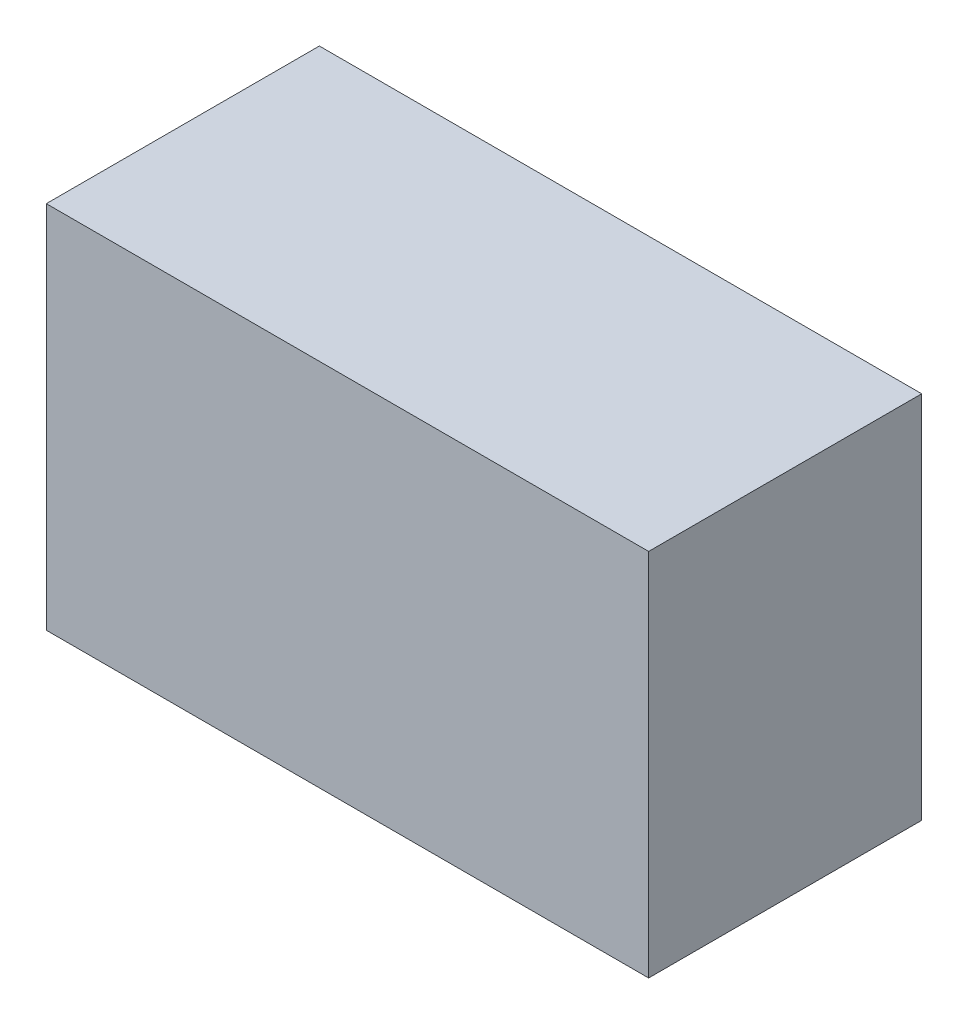
from build123d import *

# Parameters (mm, degrees)
SKETCH_2_W      = 75
SKETCH_2_H      = 34
EXTRUDE_1_DEPTH = 46


with BuildPart() as part:
    # 草图2 → 凸台-拉伸1 (new body)
    with BuildSketch(Plane(origin=(0, 0, 0), x_dir=(1, 0, 0), z_dir=(0, 1, 0))):
        Rectangle(SKETCH_2_W, SKETCH_2_H)
    extrude(amount=EXTRUDE_1_DEPTH)


solid = part.part
